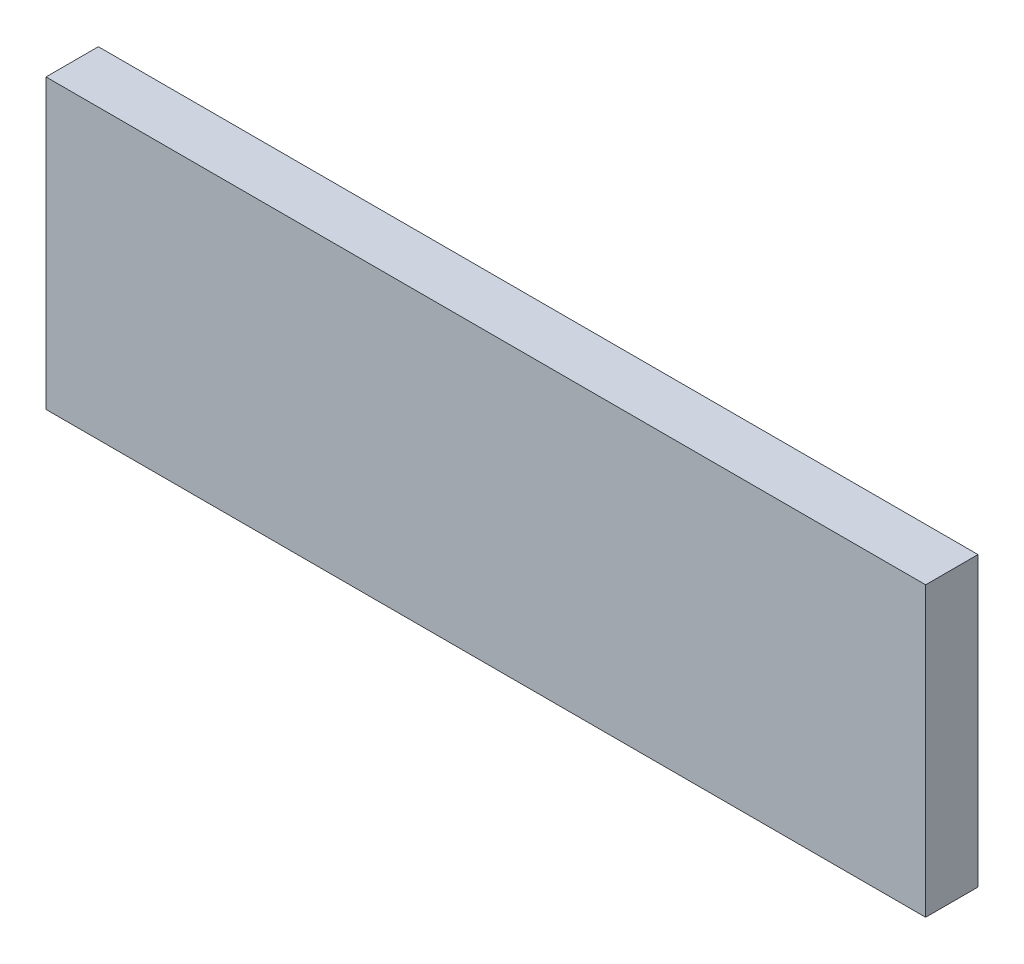
from build123d import *

# Parameters (mm, degrees)
ESQUISSE1_W        = 168
ESQUISSE1_H        = 55
BOSS_EXTRU_1_DEPTH = 10


with BuildPart() as part:
    # Esquisse1 → Boss.-Extru.1 (new body)
    with BuildSketch(Plane.XY):
        with Locations((-4.096499894, 169.236292428)):
            Rectangle(ESQUISSE1_W, ESQUISSE1_H)
    extrude(amount=BOSS_EXTRU_1_DEPTH)


solid = part.part
